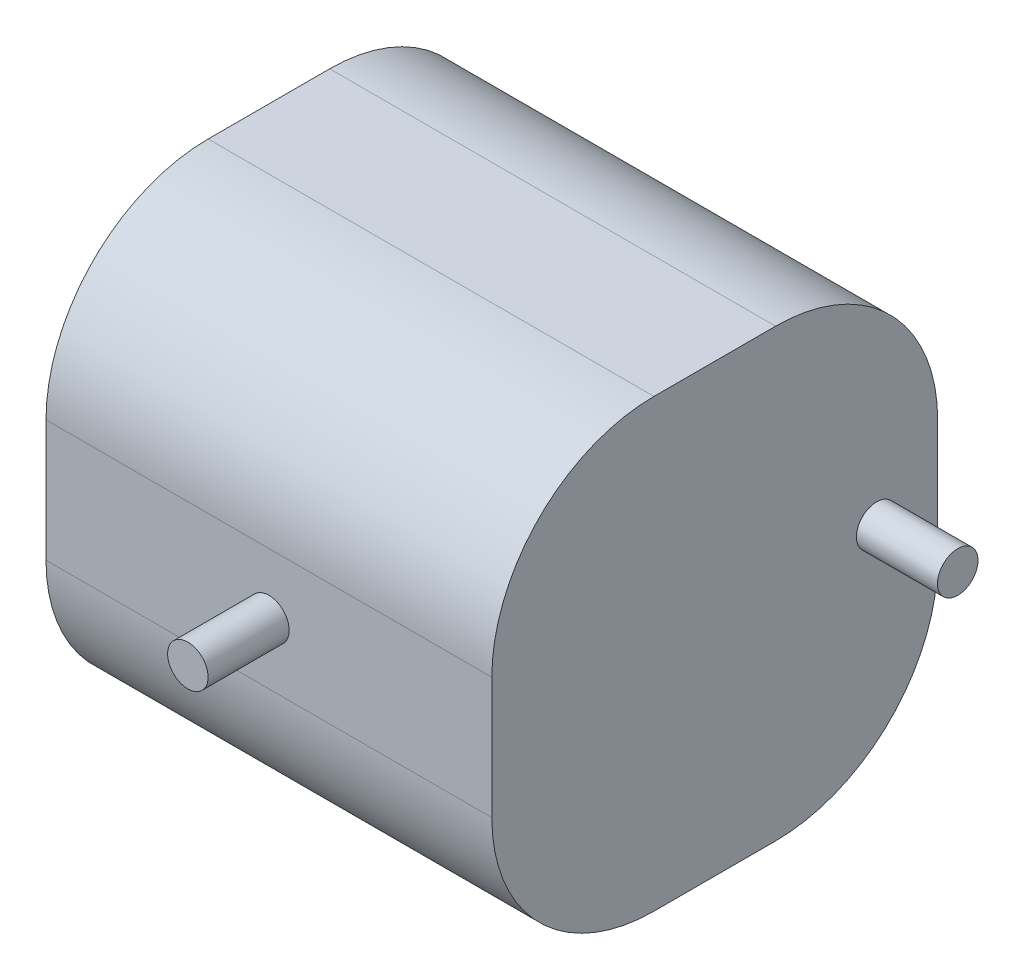
from build123d import *

# Parameters (mm, degrees)
SKETCH_1_W      = 55
SKETCH_1_H      = 55
EXTRUDE_1_DEPTH = 55
SKETCH_2_R      = 2.5
EXTRUDE_2_DEPTH = 10
SKETCH_3_R      = 2.5
EXTRUDE_3_DEPTH = 10
FILLET_1_R      = 20


with BuildPart() as part:
    # Эскиз1 → Бобышка-Вытянуть1 (new body)
    with BuildSketch(Plane.XY):
        with Locations((-11.523913591, 5.040193617)):
            Rectangle(SKETCH_1_W, SKETCH_1_H)
    extrude(amount=EXTRUDE_1_DEPTH)

    # Эскиз2 → Бобышка-Вытянуть2 (add)
    with BuildSketch(Plane(origin=(15.976086409, 0, 0), x_dir=(0, 0, -1), z_dir=(1, 0, 0))):
        with Locations((-7.523581631, 5.040193617)):
            Circle(SKETCH_2_R)
    extrude(amount=EXTRUDE_2_DEPTH)

    # Эскиз3 → Бобышка-Вытянуть3 (add)
    with BuildSketch(Plane.XY.offset(55)):
        with Locations((-11.523913591, 5.040193617)):
            Circle(SKETCH_3_R)
    extrude(amount=EXTRUDE_3_DEPTH)

    # Скругление1
    fillet_1_edges = [part.edges().sort_by_distance(p)[0] for p in [
        (-11.523913591, 32.540193617, 55),
        (-11.523913591, 32.540193617, 0),
        (-11.523913591, -22.459806383, 0),
        (-11.523913591, -22.459806383, 55),
    ]]
    fillet(fillet_1_edges, radius=FILLET_1_R)


solid = part.part
